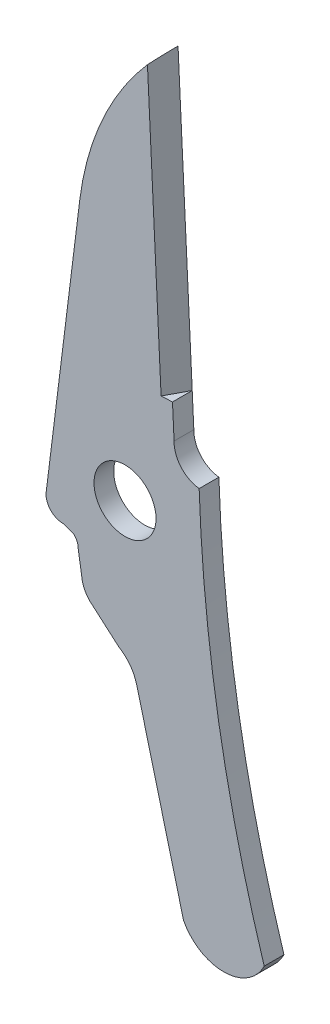
from build123d import *

# Parameters (mm, degrees)
SKETCH1_R           = 1.397
BOSS_EXTRUDE1_DEPTH = 0.4445
CUT_EXTRUDE4_DEPTH  = 16.51


with BuildPart() as part:
    # Sketch1 → Boss-Extrude1 (new body, symmetric)
    with BuildSketch(Plane.XY):
        with BuildLine():
            Line((9.00284972, 22.726912505), (9.71404972, 8.121912505))
            ThreePointArc((9.71404972, 8.121912505), (10.028030629, 7.257996655), (10.842675562, 6.832217089))
            ThreePointArc((10.842675562, 6.832217089), (11.725921803, -1.84754774), (13.772182249, -10.328777579))
            ThreePointArc((13.772182249, -10.328777579), (11.964609342, -11.463582415), (10.13976202, -10.356769839))
            Line((10.13976202, -10.356769839), (8.031181239, -2.228769839))
            ThreePointArc((8.031181239, -2.228769839), (7.732027762, -1.607745785), (7.219155962, -1.147174187))
            Line((7.219155962, -1.147174187), (6.050755962, -0.131174187))
            ThreePointArc((6.050755962, -0.131174187), (5.704248725, 0.270738994), (5.552221275, 0.779157252))
            Line((5.552221275, 0.779157252), (5.396674082, 1.769757252))
            ThreePointArc((5.396674082, 1.769757252), (5.343412822, 2.024518698), (5.192550751, 2.236605453))
            Line((5.192550751, 2.236605453), (4.709950751, 2.404757252))
            ThreePointArc((4.709950751, 2.404757252), (4.121509293, 2.682628498), (3.962230463, 3.313584941))
            Line((3.962230463, 3.313584941), (5.467671494, 15.403984941))
            ThreePointArc((5.467671494, 15.403984941), (6.633327736, 19.356034689), (9.00284972, 22.726912505))
        make_face()
        with Locations((7.503950751, 4.690757252)):
            Circle(SKETCH1_R, mode=Mode.SUBTRACT)
    extrude(amount=BOSS_EXTRUDE1_DEPTH, both=True)

    # Sketch2 → Cut-Extrude4 (cut)
    with BuildSketch(Plane(origin=(-1.247053398, 25.609132285, 0), x_dir=(0.998816471, 0.048638019, 0), z_dir=(-0.048638019, 0.998816471, 0))):
        Polygon((10.097586601, 0.4445), (10.097586601, -0.4445), (9.584322211, -0.4445), align=None)
    extrude(amount=-CUT_EXTRUDE4_DEPTH, mode=Mode.SUBTRACT)


solid = part.part
